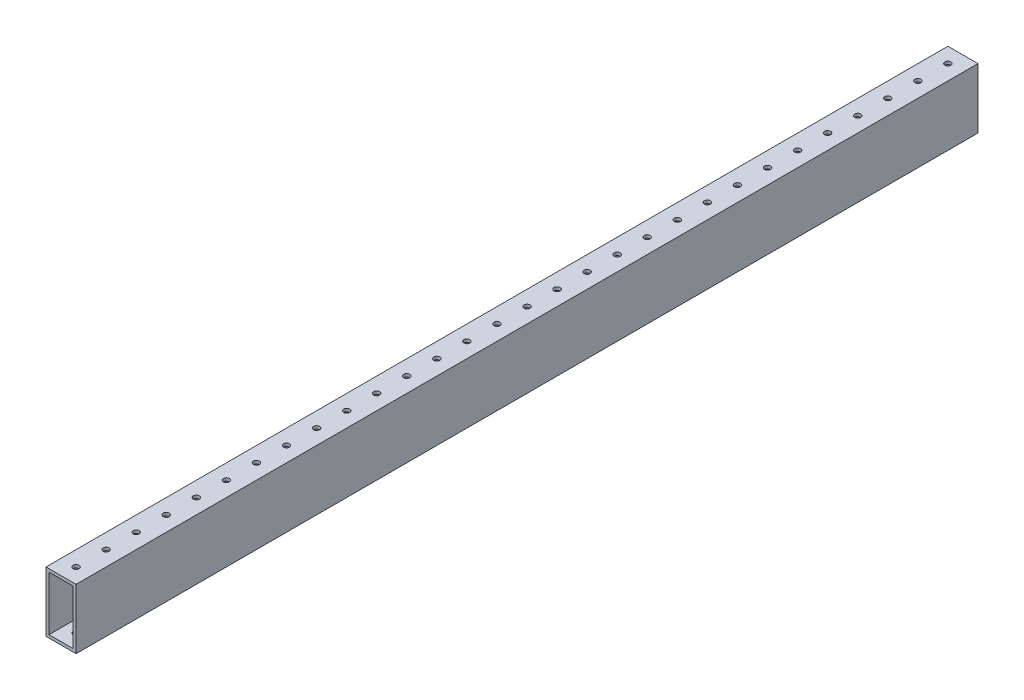
from build123d import *

# Parameters (mm, degrees)
SKETCH2_W           = 25.4
SKETCH2_H           = 762
SKETCH2_R           = 2.54
BOSS_EXTRUDE1_DEPTH = 50.8
SKETCH3_OUTSIDE_W   = 180.222
SKETCH3_OUTSIDE_H   = 205.622
SKETCH3_OUTSIDE_W_2 = 25.4
SKETCH3_OUTSIDE_H_2 = 50.8
SKETCH3_OUTSIDE_W_3 = 20.32
SKETCH3_OUTSIDE_H_3 = 45.72
CUT_EXTRUDE1_DEPTH  = 763


with BuildPart() as part:
    # Sketch2 → Boss-Extrude1 (new body)
    with BuildSketch(Plane(origin=(0, 0, 0), x_dir=(1, 0, 0), z_dir=(0, 1, 0))):
        with Locations((12.7, 381)):
            Rectangle(SKETCH2_W, SKETCH2_H)
        with Locations((12.7, 12.7)):
            Circle(SKETCH2_R, mode=Mode.SUBTRACT)
        with Locations((12.7, 38.1)):
            Circle(SKETCH2_R, mode=Mode.SUBTRACT)
        with Locations((12.7, 63.5)):
            Circle(SKETCH2_R, mode=Mode.SUBTRACT)
        with Locations((12.7, 88.9)):
            Circle(SKETCH2_R, mode=Mode.SUBTRACT)
        with Locations((12.7, 114.3)):
            Circle(SKETCH2_R, mode=Mode.SUBTRACT)
        with Locations((12.7, 139.7)):
            Circle(SKETCH2_R, mode=Mode.SUBTRACT)
        with Locations((12.7, 165.1)):
            Circle(SKETCH2_R, mode=Mode.SUBTRACT)
        with Locations((12.7, 190.5)):
            Circle(SKETCH2_R, mode=Mode.SUBTRACT)
        with Locations((12.7, 215.9)):
            Circle(SKETCH2_R, mode=Mode.SUBTRACT)
        with Locations((12.7, 241.3)):
            Circle(SKETCH2_R, mode=Mode.SUBTRACT)
        with Locations((12.7, 266.7)):
            Circle(SKETCH2_R, mode=Mode.SUBTRACT)
        with Locations((12.7, 292.1)):
            Circle(SKETCH2_R, mode=Mode.SUBTRACT)
        with Locations((12.7, 317.5)):
            Circle(SKETCH2_R, mode=Mode.SUBTRACT)
        with Locations((12.7, 342.9)):
            Circle(SKETCH2_R, mode=Mode.SUBTRACT)
        with Locations((12.7, 368.3)):
            Circle(SKETCH2_R, mode=Mode.SUBTRACT)
        with Locations((12.7, 393.7)):
            Circle(SKETCH2_R, mode=Mode.SUBTRACT)
        with Locations((12.7, 419.1)):
            Circle(SKETCH2_R, mode=Mode.SUBTRACT)
        with Locations((12.7, 444.5)):
            Circle(SKETCH2_R, mode=Mode.SUBTRACT)
        with Locations((12.7, 469.9)):
            Circle(SKETCH2_R, mode=Mode.SUBTRACT)
        with Locations((12.7, 495.3)):
            Circle(SKETCH2_R, mode=Mode.SUBTRACT)
        with Locations((12.7, 520.7)):
            Circle(SKETCH2_R, mode=Mode.SUBTRACT)
        with Locations((12.7, 546.1)):
            Circle(SKETCH2_R, mode=Mode.SUBTRACT)
        with Locations((12.7, 571.5)):
            Circle(SKETCH2_R, mode=Mode.SUBTRACT)
        with Locations((12.7, 596.9)):
            Circle(SKETCH2_R, mode=Mode.SUBTRACT)
        with Locations((12.7, 622.3)):
            Circle(SKETCH2_R, mode=Mode.SUBTRACT)
        with Locations((12.7, 647.7)):
            Circle(SKETCH2_R, mode=Mode.SUBTRACT)
        with Locations((12.7, 673.1)):
            Circle(SKETCH2_R, mode=Mode.SUBTRACT)
        with Locations((12.7, 698.5)):
            Circle(SKETCH2_R, mode=Mode.SUBTRACT)
        with Locations((12.7, 723.9)):
            Circle(SKETCH2_R, mode=Mode.SUBTRACT)
        with Locations((12.7, 749.3)):
            Circle(SKETCH2_R, mode=Mode.SUBTRACT)
    extrude(amount=BOSS_EXTRUDE1_DEPTH)

    # Sketch3 outside → Cut-Extrude1 (cut, through all)
    with BuildSketch(Plane.XY):
        with Locations((12.7, 25.4)):
            Rectangle(SKETCH3_OUTSIDE_W, SKETCH3_OUTSIDE_H)
        with Locations((12.7, 25.4)):
            Rectangle(SKETCH3_OUTSIDE_W_2, SKETCH3_OUTSIDE_H_2, mode=Mode.SUBTRACT)
        with Locations((12.7, 25.4)):
            Rectangle(SKETCH3_OUTSIDE_W_3, SKETCH3_OUTSIDE_H_3)
    extrude(amount=-CUT_EXTRUDE1_DEPTH, mode=Mode.SUBTRACT)


solid = part.part
